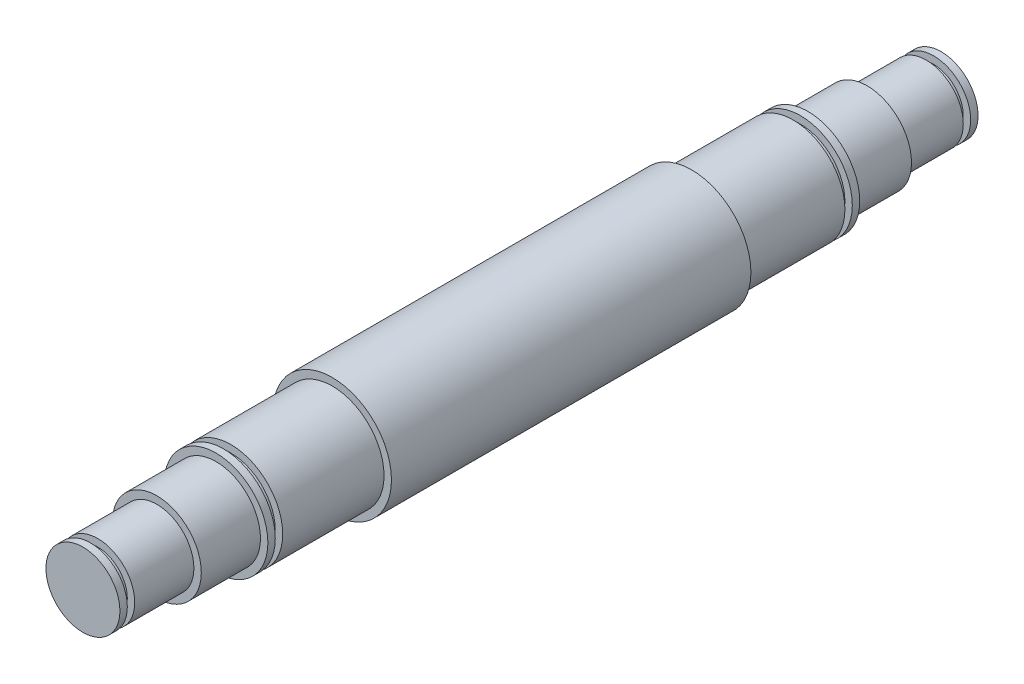
from build123d import *

# Parameters (mm, degrees)
SKETCH2_R            = 15.875
BOSS_EXTRUDE1_DEPTH  = 25.4
SKETCH4_R            = 19.05
BOSS_EXTRUDE2_DEPTH  = 25.4
SKETCH5_R            = 22.225
BOSS_EXTRUDE3_DEPTH  = 3.175
SKETCH6_R            = 19.05
BOSS_EXTRUDE4_DEPTH  = 3.175
SKETCH7_R            = 22.225
BOSS_EXTRUDE5_DEPTH  = 43.5102
SKETCH8_R            = 25.4
BOSS_EXTRUDE6_DEPTH  = 77.1398
CUT_EXTRUDE1_DEPTH   = 3.175
SKETCH10_R           = 12.7
BOSS_EXTRUDE7_DEPTH  = 3.175
SKETCH11_R           = 15.875
BOSS_EXTRUDE8_DEPTH  = 3.175
SKETCH12_R           = 12.7
BOSS_EXTRUDE9_DEPTH  = 3.175
SKETCH13_R           = 15.875
BOSS_EXTRUDE10_DEPTH = 3.175


with BuildPart() as part:
    # Sketch2 → Boss-Extrude1 (new body)
    with BuildSketch(Plane.XY):
        Circle(SKETCH2_R)
    extrude(amount=BOSS_EXTRUDE1_DEPTH)

    # Sketch4 → Boss-Extrude2 (add)
    with BuildSketch(Plane.XY.offset(25.4)):
        Circle(SKETCH4_R)
    extrude(amount=BOSS_EXTRUDE2_DEPTH)

    # Sketch5 → Boss-Extrude3 (add)
    with BuildSketch(Plane.XY.offset(50.8)):
        Circle(SKETCH5_R)
    extrude(amount=BOSS_EXTRUDE3_DEPTH)

    # Sketch6 → Boss-Extrude4 (add)
    with BuildSketch(Plane.XY.offset(53.975)):
        Circle(SKETCH6_R)
    extrude(amount=BOSS_EXTRUDE4_DEPTH)

    # Sketch7 → Boss-Extrude5 (add)
    with BuildSketch(Plane.XY.offset(57.15)):
        Circle(SKETCH7_R)
    extrude(amount=BOSS_EXTRUDE5_DEPTH)

    # Sketch8 → Boss-Extrude6 (add)
    with BuildSketch(Plane.XY.offset(100.6602)):
        Circle(SKETCH8_R)
    extrude(amount=BOSS_EXTRUDE6_DEPTH)

    # Sketch9 → Cut-Extrude1 (cut)
    with BuildSketch(Plane(origin=(0, -22.225, 0), x_dir=(-1, 0, 0), z_dir=(0, -1, 0))):
        with BuildLine():
            Line((3.175, -69.3801), (3.175, -88.4301))
            ThreePointArc((3.175, -88.4301), (0, -91.6051), (-3.175, -88.4301))
            Line((-3.175, -88.4301), (-3.175, -69.3801))
            ThreePointArc((-3.175, -69.3801), (0, -66.2051), (3.175, -69.3801))
        make_face()
    extrude(amount=-CUT_EXTRUDE1_DEPTH, mode=Mode.SUBTRACT)

    # Mirror1: part across plane


with BuildPart() as part_1:
    add(part.part)
    add(part.part.mirror(Plane.XY.offset(177.8)))

    # Sketch10 → Boss-Extrude7 (add)
    with BuildSketch(Plane(origin=(0, 0, 0), x_dir=(-1, 0, 0), z_dir=(0, 0, -1))):
        Circle(SKETCH10_R)
    extrude(amount=BOSS_EXTRUDE7_DEPTH)

    # Sketch11 → Boss-Extrude8 (add)
    with BuildSketch(Plane(origin=(0, 0, -3.175), x_dir=(-1, 0, 0), z_dir=(0, 0, -1))):
        Circle(SKETCH11_R)
    extrude(amount=BOSS_EXTRUDE8_DEPTH)

    # Sketch12 → Boss-Extrude9 (add)
    with BuildSketch(Plane.XY.offset(355.6)):
        Circle(SKETCH12_R)
    extrude(amount=BOSS_EXTRUDE9_DEPTH)

    # Sketch13 → Boss-Extrude10 (add)
    with BuildSketch(Plane.XY.offset(358.775)):
        Circle(SKETCH13_R)
    extrude(amount=BOSS_EXTRUDE10_DEPTH)


solid = part_1.part
